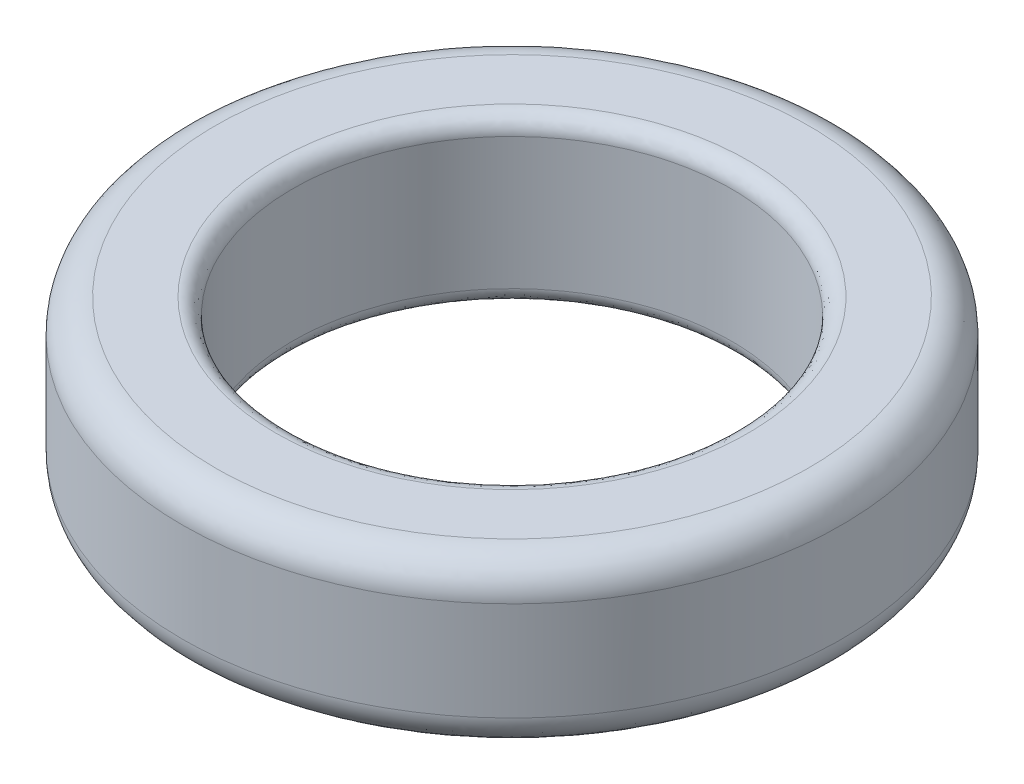
from build123d import *

# Parameters (mm, degrees)
SKETCH1_R           = 30
SKETCH1_R_2         = 20
BOSS_EXTRUDE1_DEPTH = 15
FILLET1_R           = 3
FILLET2_R           = 1.5


with BuildPart() as part:
    # Sketch1 → Boss-Extrude1 (new body)
    with BuildSketch(Plane(origin=(0, 0, 0), x_dir=(1, 0, 0), z_dir=(0, 1, 0))):
        Circle(SKETCH1_R)
        Circle(SKETCH1_R_2, mode=Mode.SUBTRACT)
    extrude(amount=BOSS_EXTRUDE1_DEPTH)

    # Fillet1
    fillet1_edges = [part.edges().sort_by_distance(p)[0] for p in [
        (-30, 0, 0),
        (-30, 15, 0),
    ]]
    fillet(fillet1_edges, radius=FILLET1_R)

    # Fillet2
    fillet2_edges = [part.edges().sort_by_distance(p)[0] for p in [
        (-20, 0, 0),
        (-20, 15, 0),
    ]]
    fillet(fillet2_edges, radius=FILLET2_R)


solid = part.part
